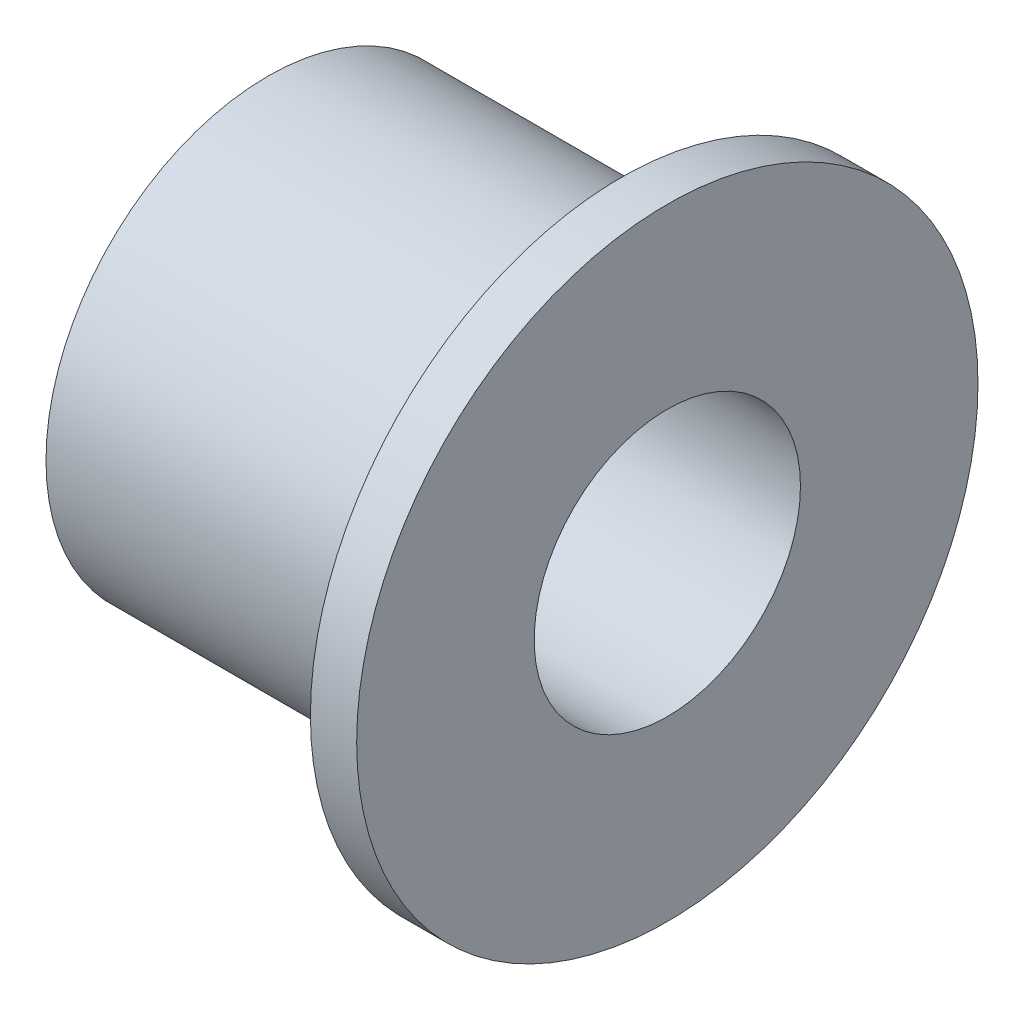
from build123d import *

# Parameters (mm, degrees)
SKETCH1_R                = 7.9375
SKETCH1_R_2              = 4.7625
BOSS_EXTRUDE1_DEPTH      = 12.7
SKETCH2_R                = 11.1125
SKETCH2_R_2              = 4.7625
BOSS_EXTRUDE2_DEPTH      = 1.5875
BOSS_EXTRUDE2_DEPTH_BACK = 0.067225321


with BuildPart() as part:
    # Sketch1 → Boss-Extrude1 (new body)
    with BuildSketch(Plane(origin=(0, 0, 0), x_dir=(0, 0, -1), z_dir=(1, 0, 0))):
        Circle(SKETCH1_R)
        Circle(SKETCH1_R_2, mode=Mode.SUBTRACT)
    extrude(amount=BOSS_EXTRUDE1_DEPTH)

    # Sketch2 → Boss-Extrude2 (add, two sides)
    with BuildSketch(Plane(origin=(12.7, 0, 0), x_dir=(0, 0, -1), z_dir=(1, 0, 0))) as boss_extrude2_sk:
        Circle(SKETCH2_R)
        Circle(SKETCH2_R_2, mode=Mode.SUBTRACT)
    extrude(amount=BOSS_EXTRUDE2_DEPTH)
    extrude(boss_extrude2_sk.sketch, amount=-BOSS_EXTRUDE2_DEPTH_BACK)


solid = part.part
